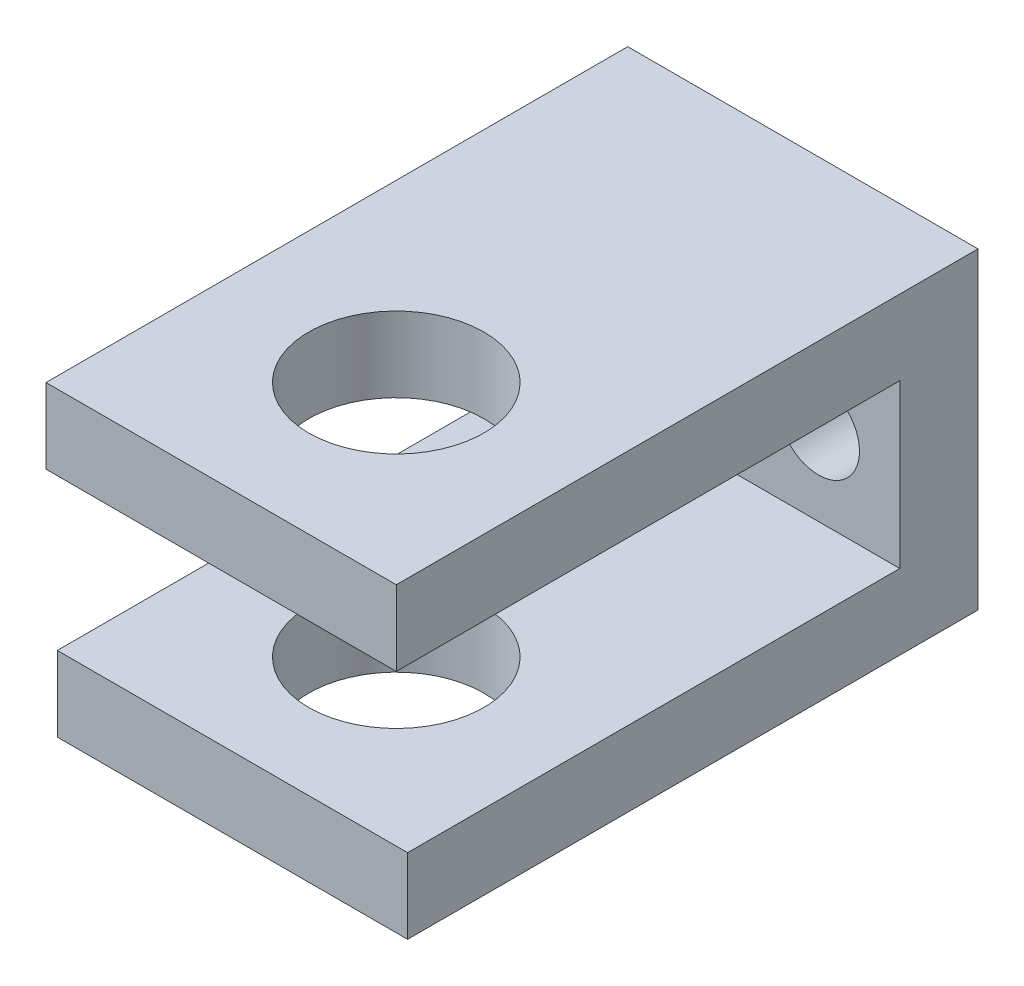
from build123d import *

# Parameters (mm, degrees)
SKETCH1_W                 = 14.224
SKETCH1_H                 = 23.622
BOSS_EXTRUDE1_DEPTH       = 3.048
SKETCH2_W                 = 3.175
SKETCH2_H                 = 6.604
MIDDLE_DEPTH              = 14.224
SKETCH3_W                 = 14.224
SKETCH3_H                 = 23.162672358
BOTTOM_DEPTH              = 3.048
SKETCH4_R                 = 3.556
HOLE_FOR_CLEVIS_PIN_DEPTH = 13.7
SKETCH5_R                 = 1.6637
HOLES_FOR_SCREWS_DEPTH    = 24.622


with BuildPart() as part:
    # Sketch1 → Boss-Extrude1 (new body)
    with BuildSketch(Plane(origin=(0, 0, 0), x_dir=(1, 0, 0), z_dir=(0, 1, 0))):
        Rectangle(SKETCH1_W, SKETCH1_H)
    extrude(amount=BOSS_EXTRUDE1_DEPTH)

    # Sketch2 → middle (add)
    with BuildSketch(Plane(origin=(7.112, 0, 0), x_dir=(0, 0, -1), z_dir=(1, 0, 0))):
        with Locations((10.2235, -3.302)):
            Rectangle(SKETCH2_W, SKETCH2_H)
    extrude(amount=-MIDDLE_DEPTH)

    # Sketch3 → bottom (add)
    with BuildSketch(Plane.XZ.offset(6.604)):
        with Locations((0, -0.229663821)):
            Rectangle(SKETCH3_W, SKETCH3_H)
    extrude(amount=BOTTOM_DEPTH)

    # Sketch4 → hole for clevis pin (cut, through all)
    with BuildSketch(Plane(origin=(0, 3.048, 0), x_dir=(1, 0, 0), z_dir=(0, 1, 0))):
        with Locations((0, -4.699)):
            Circle(SKETCH4_R)
    extrude(amount=-HOLE_FOR_CLEVIS_PIN_DEPTH, mode=Mode.SUBTRACT)

    # Sketch5 → holes for screws (cut, through all)
    with BuildSketch(Plane(origin=(0, 0, -11.811), x_dir=(-1, 0, 0), z_dir=(0, 0, -1))):
        with Locations((-3.81, -3.302)):
            Circle(SKETCH5_R)
        with Locations((3.81, -3.302)):
            Circle(SKETCH5_R)
    extrude(amount=-HOLES_FOR_SCREWS_DEPTH, mode=Mode.SUBTRACT)


solid = part.part
